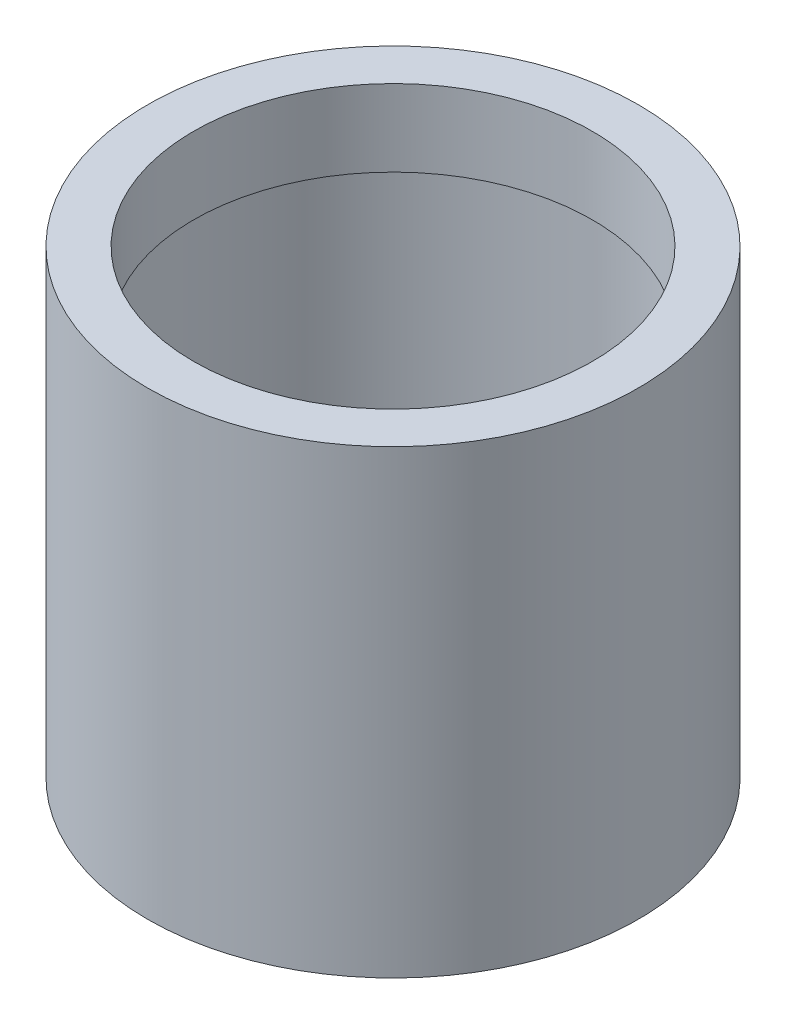
from build123d import *

# Parameters (mm, degrees)
SKETCH1_R           = 16
SKETCH1_R_2         = 14.5
BOSS_EXTRUDE1_DEPTH = 25
SKETCH2_R           = 16
SKETCH2_R_2         = 13
BOSS_EXTRUDE2_DEPTH = 5


with BuildPart() as part:
    # Sketch1 → Boss-Extrude1 (new body)
    with BuildSketch(Plane(origin=(0, 0, 0), x_dir=(1, 0, 0), z_dir=(0, 1, 0))):
        Circle(SKETCH1_R)
        Circle(SKETCH1_R_2, mode=Mode.SUBTRACT)
    extrude(amount=BOSS_EXTRUDE1_DEPTH)

    # Sketch2 → Boss-Extrude2 (add)
    with BuildSketch(Plane(origin=(0, 25, 0), x_dir=(1, 0, 0), z_dir=(0, 1, 0))):
        Circle(SKETCH2_R)
        Circle(SKETCH2_R_2, mode=Mode.SUBTRACT)
    extrude(amount=BOSS_EXTRUDE2_DEPTH)


solid = part.part
